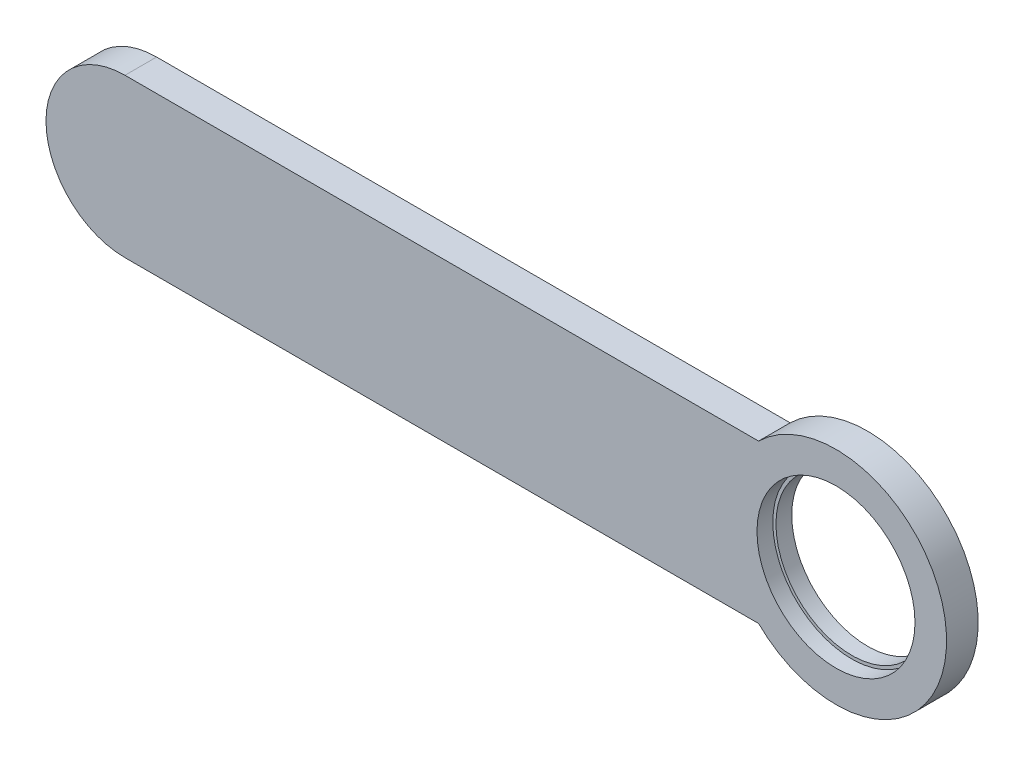
from build123d import *

# Parameters (mm, degrees)
ESQUISSE1_R             = 50
BOSS_EXTRU_1_DEPTH      = 20
ESQUISSE2_R             = 50
ESQUISSE2_R_2           = 48
BOSS_EXTRU_2_DEPTH      = 10
ESQUISSE3_OUTSIDE_W     = 713.342
ESQUISSE3_OUTSIDE_H     = 263.342
ENL_V_MAT_EXTRU_1_DEPTH = 21


with BuildPart() as part:
    # Esquisse1 → Boss.-Extru.1 (new body)
    with BuildSketch(Plane.XY):
        with BuildLine():
            Line((0, -70), (-450, -70))
            ThreePointArc((-450, -70), (-520, 0), (-450, 70))
            Line((-450, 70), (0, 70))
            ThreePointArc((0, 70), (70, 0), (0, -70))
        make_face()
        Circle(ESQUISSE1_R, mode=Mode.SUBTRACT)
    extrude(amount=BOSS_EXTRU_1_DEPTH)

    # Esquisse2 → Boss.-Extru.2 (add)
    with BuildSketch(Plane(origin=(0, 0, 0), x_dir=(-1, 0, 0), z_dir=(0, 0, -1))):
        Circle(ESQUISSE2_R)
        Circle(ESQUISSE2_R_2, mode=Mode.SUBTRACT)
    extrude(amount=-BOSS_EXTRU_2_DEPTH)

    # Esquisse3 outside → Enlèv. mat.-Extru.1 (cut, through all)
    with BuildSketch(Plane(origin=(0, 0, 0), x_dir=(-1, 0, 0), z_dir=(0, 0, -1))):
        with Locations((225, 0)):
            Rectangle(ESQUISSE3_OUTSIDE_W, ESQUISSE3_OUTSIDE_H)
        with BuildLine():
            Line((450, -50), (48.989794856, -50))
            ThreePointArc((48.989794856, -50), (-70, 0), (48.989794856, 50))
            Line((48.989794856, 50), (450, 50))
            ThreePointArc((450, 50), (500, 0), (450, -50))
        make_face(mode=Mode.SUBTRACT)
    extrude(amount=-ENL_V_MAT_EXTRU_1_DEPTH, mode=Mode.SUBTRACT)


solid = part.part
